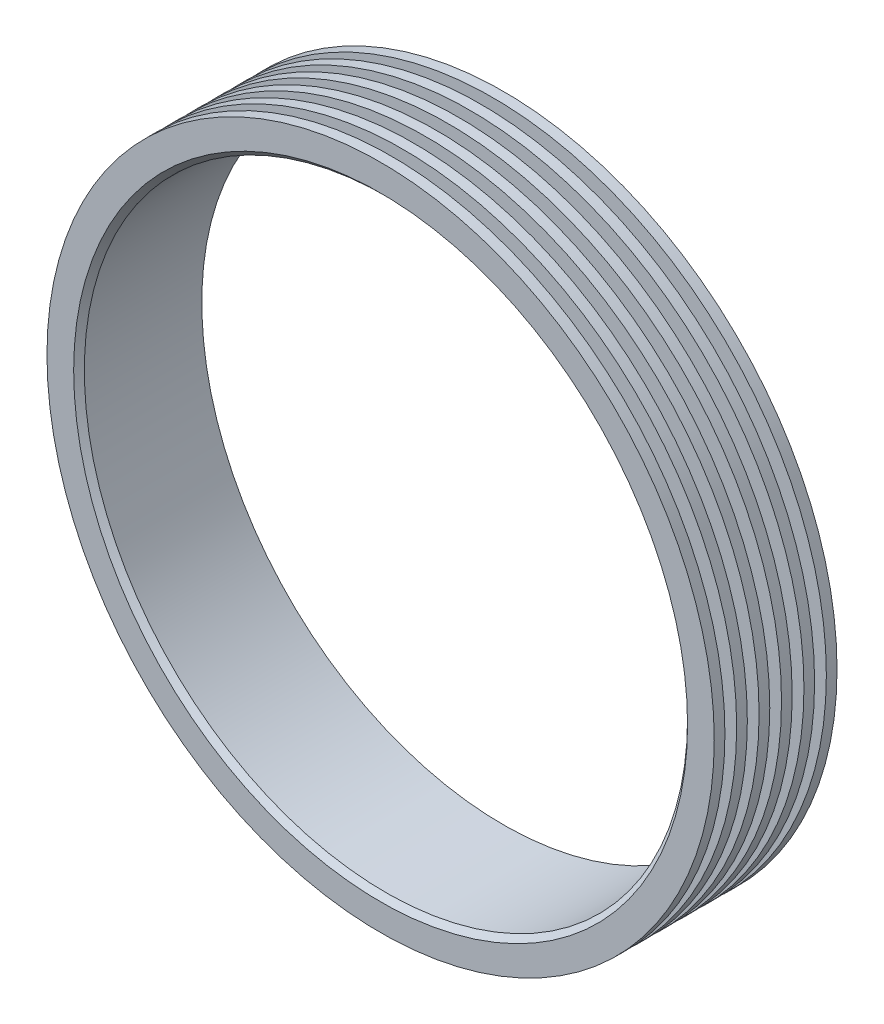
from build123d import *


with BuildPart() as part:
    # Schizzo2 → Rivoluzione1 (revolve)
    with BuildSketch(Plane(origin=(0, 0, 0), x_dir=(0, 0, -1), z_dir=(1, 0, 0))):
        Polygon((0, 56.5), (-10.5, 56.5), (-11.5, 57.5), (-11.5, 62.5), (-9.5, 62.5), (-9.5, 58.5), (-7.3, 58.5), (-7.3, 62.5), (-5.3, 62.5), (-5.3, 58.5), (-3.1, 58.5), (-3.1, 62.5), (-1.1, 62.5), (-1.1, 58.5), (1.1, 58.5), (1.1, 62.5), (3.1, 62.5), (3.1, 58.5), (5.3, 58.5), (5.3, 62.5), (7.3, 62.5), (7.3, 58.5), (9.5, 58.5), (9.5, 62.5), (11.5, 62.5), (11.5, 56.5), align=None)
    revolve(axis=Axis((0, 0, 0), (0, 0, -1)))


solid = part.part
